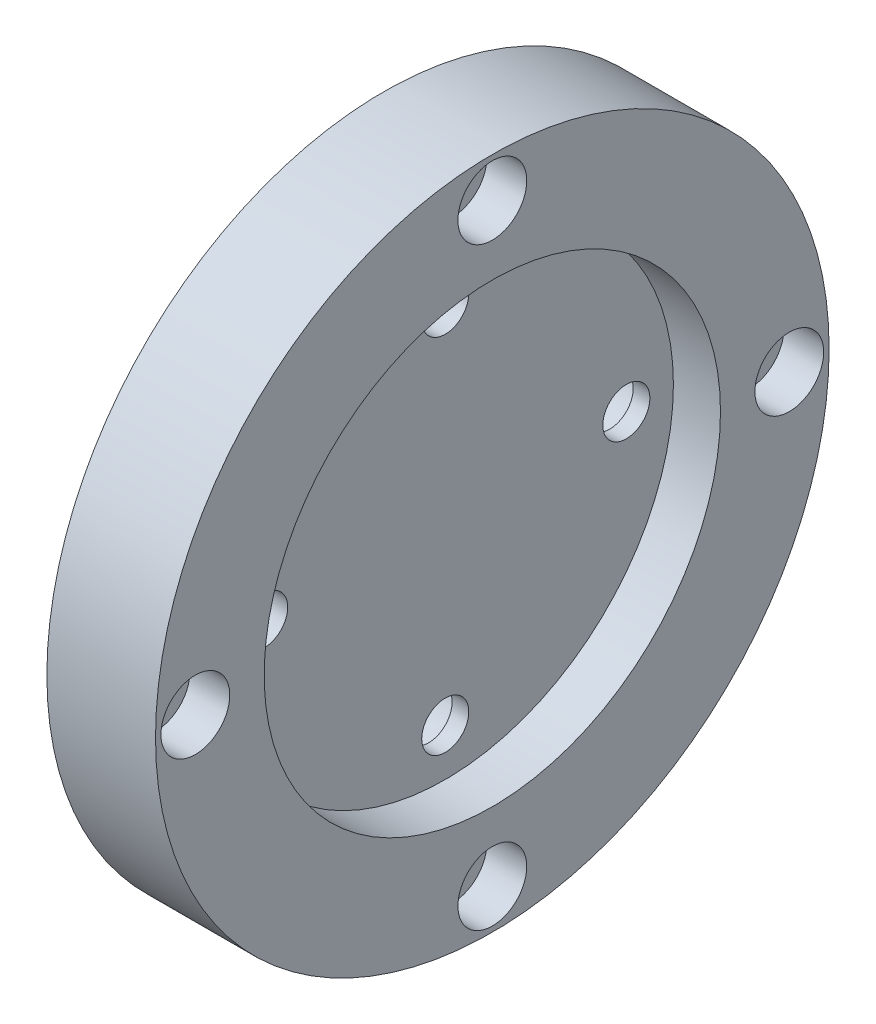
from build123d import *

# Parameters (mm, degrees)
SKETCH_1_R               = 46.5
EXTRUDE_1_DEPTH          = 15
SKETCH_2_R               = 31.5
CUT_EXTRUDE_1_DEPTH      = 6.5
SKETCH_3_R               = 3.25
CUT_EXTRUDE_2_DEPTH      = 9.5
PATTERN_CIRCULAR_1_COUNT = 4
SKETCH_4_R               = 5.5
CUT_EXTRUDE_3_DEPTH      = 6.2
SKETCH_5_R               = 2.75
CUT_EXTRUDE_4_DEPTH      = 16
PATTERN_CIRCULAR_2_COUNT = 4
SKETCH_6_R               = 4.75
CUT_EXTRUDE_5_DEPTH      = 5.5
PATTERN_CIRCULAR_3_COUNT = 4


with BuildPart() as part:
    # 草图1 → 凸台-拉伸1 (new body)
    with BuildSketch(Plane(origin=(0, 0, 0), x_dir=(0, 0, -1), z_dir=(1, 0, 0))):
        Circle(SKETCH_1_R)
    extrude(amount=EXTRUDE_1_DEPTH)

    # 草图2 → 切除-拉伸1 (cut)
    with BuildSketch(Plane(origin=(15, 0, 0), x_dir=(0, 0, -1), z_dir=(1, 0, 0))):
        Circle(SKETCH_2_R)
    extrude(amount=-CUT_EXTRUDE_1_DEPTH, mode=Mode.SUBTRACT)

    # 草图3 → 切除-拉伸2 (cut, through all)
    with BuildSketch(Plane(origin=(8.5, 0, 0), x_dir=(0, 0, -1), z_dir=(1, 0, 0))):
        with Locations((0, 25)):
            Circle(SKETCH_3_R)
    cut_extrude_2 = extrude(amount=-CUT_EXTRUDE_2_DEPTH, mode=Mode.SUBTRACT)

    # 阵列(圆周)1: 切除-拉伸2 ×4 about axis
    pattern_circular_1_axis = Axis((0, 0, 0), (1, 0, 0))
    for i in range(1, PATTERN_CIRCULAR_1_COUNT):
        add(cut_extrude_2.rotate(pattern_circular_1_axis, i * 360 / PATTERN_CIRCULAR_1_COUNT), mode=Mode.SUBTRACT)

    # 草图4 → 切除-拉伸3 (cut)
    with BuildSketch(Plane.ZY):
        with Locations((0, 25)):
            Circle(SKETCH_4_R)
        with Locations((-25, 0)):
            Circle(SKETCH_4_R)
        with Locations((0, -25)):
            Circle(SKETCH_4_R)
        with Locations((25, 0)):
            Circle(SKETCH_4_R)
    extrude(amount=-CUT_EXTRUDE_3_DEPTH, mode=Mode.SUBTRACT)

    # 草图5 → 切除-拉伸4 (cut, through all)
    with BuildSketch(Plane(origin=(15, 0, 0), x_dir=(0, 0, -1), z_dir=(1, 0, 0))):
        with Locations((41, 0)):
            Circle(SKETCH_5_R)
    cut_extrude_4 = extrude(amount=-CUT_EXTRUDE_4_DEPTH, mode=Mode.SUBTRACT)

    # 阵列(圆周)2: 切除-拉伸4 ×4 about axis
    pattern_circular_2_axis = Axis((0, 0, 0), (1, 0, 0))
    for i in range(1, PATTERN_CIRCULAR_2_COUNT):
        add(cut_extrude_4.rotate(pattern_circular_2_axis, i * 360 / PATTERN_CIRCULAR_2_COUNT), mode=Mode.SUBTRACT)

    # 草图6 → 切除-拉伸5 (cut)
    with BuildSketch(Plane(origin=(15, 0, 0), x_dir=(0, 0, -1), z_dir=(1, 0, 0))):
        with Locations((0, -41)):
            Circle(SKETCH_6_R)
    cut_extrude_5 = extrude(amount=-CUT_EXTRUDE_5_DEPTH, mode=Mode.SUBTRACT)

    # 阵列(圆周)3: 切除-拉伸5 ×4 about axis
    pattern_circular_3_axis = Axis((0, 0, 0), (1, 0, 0))
    for i in range(1, PATTERN_CIRCULAR_3_COUNT):
        add(cut_extrude_5.rotate(pattern_circular_3_axis, i * 360 / PATTERN_CIRCULAR_3_COUNT), mode=Mode.SUBTRACT)


solid = part.part
